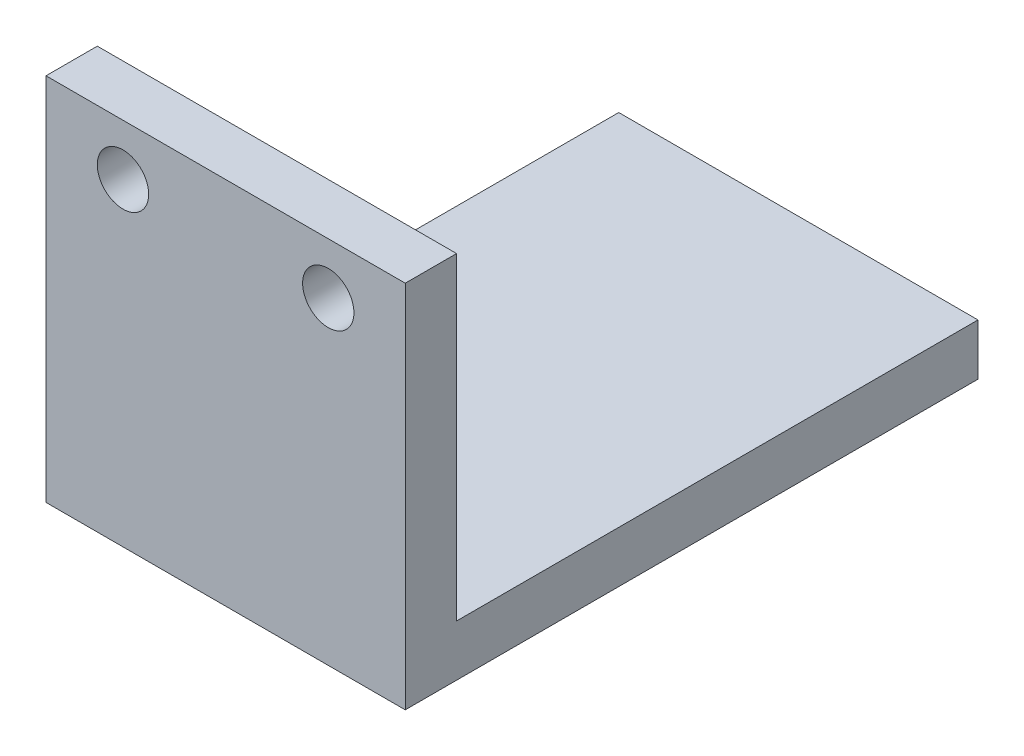
from build123d import *

# Parameters (mm, degrees)
SKETCH1_R           = 2.5
BOSS_EXTRUDE1_DEPTH = 5
SKETCH2_W           = 35
SKETCH2_H           = 55.8
SKETCH2_R           = 1.25
BOSS_EXTRUDE2_DEPTH = 5


with BuildPart() as part:
    # Sketch1 → Boss-Extrude1 (new body)
    with BuildSketch(Plane.XY):
        Polygon((-17.5, 5), (17.5, 5), (17.5, -5), (17.5, -26), (-17.5, -26), (-17.5, -5), align=None)
        with Locations((-10, 0)):
            Circle(SKETCH1_R, mode=Mode.SUBTRACT)
        with Locations((10, 0)):
            Circle(SKETCH1_R, mode=Mode.SUBTRACT)
    extrude(amount=BOSS_EXTRUDE1_DEPTH)

    # Sketch2 → Boss-Extrude2 (add)
    with BuildSketch(Plane.XZ.offset(26)):
        with Locations((0, -22.9)):
            Rectangle(SKETCH2_W, SKETCH2_H)
        with Locations((-12.5, -22.4)):
            Circle(SKETCH2_R, mode=Mode.SUBTRACT)
    extrude(amount=BOSS_EXTRUDE2_DEPTH)


solid = part.part
